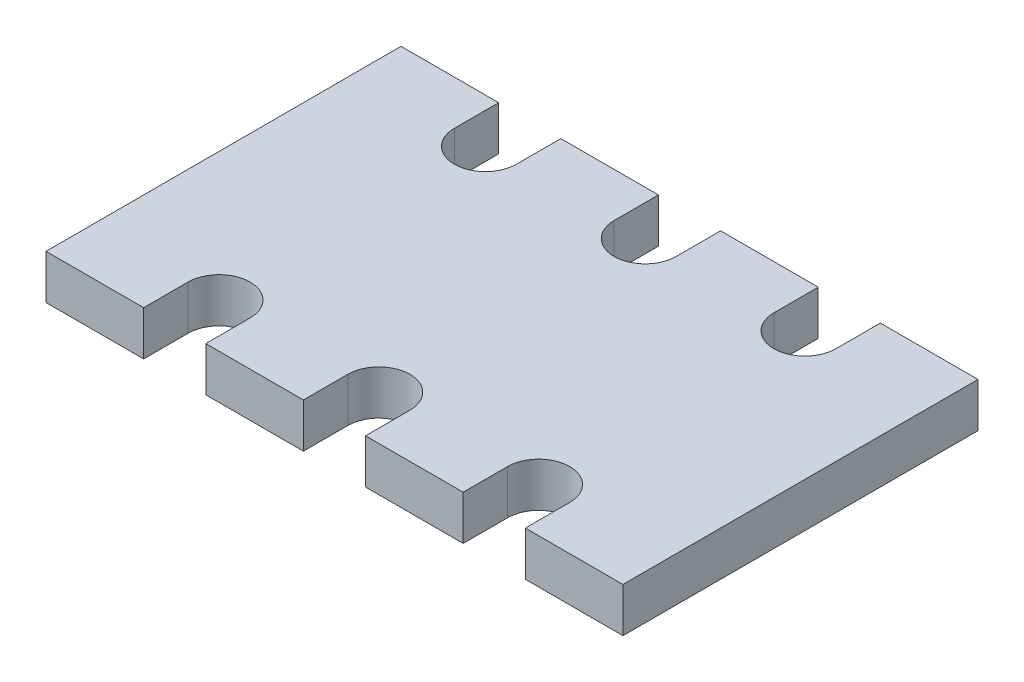
from build123d import *

# Parameters (mm, degrees)
BOSS_EXTRUDE1_DEPTH = 0.5


with BuildPart() as part:
    # Sketch1 → Boss-Extrude1 (new body)
    with BuildSketch(Plane(origin=(0, 0, 0), x_dir=(1, 0, 0), z_dir=(0, 1, 0))):
        with BuildLine():
            Line((-5.4, 0), (-5.4, -0.5))
            ThreePointArc((-5.4, -0.5), (-5.05, -0.85), (-4.7, -0.5))
            Line((-4.7, -0.5), (-4.7, 0))
            Line((-4.7, 0), (-3.6, 0))
            Line((-3.6, 0), (-3.6, -0.5))
            ThreePointArc((-3.6, -0.5), (-3.25, -0.85), (-2.9, -0.5))
            Line((-2.9, -0.5), (-2.9, 0))
            Line((-2.9, 0), (-1.8, 0))
            Line((-1.8, 0), (-1.8, -0.5))
            ThreePointArc((-1.8, -0.5), (-1.45, -0.85), (-1.1, -0.5))
            Line((-1.1, -0.5), (-1.1, 0))
            Line((-1.1, 0), (0, 0))
            Line((0, 0), (0, -4))
            Line((0, -4), (-1.1, -4))
            Line((-1.1, -4), (-1.1, -3.5))
            ThreePointArc((-1.1, -3.5), (-1.45, -3.15), (-1.8, -3.5))
            Line((-1.8, -3.5), (-1.8, -4))
            Line((-1.8, -4), (-2.9, -4))
            Line((-2.9, -4), (-2.9, -3.5))
            ThreePointArc((-2.9, -3.5), (-3.25, -3.15), (-3.6, -3.5))
            Line((-3.6, -3.5), (-3.6, -4))
            Line((-3.6, -4), (-4.7, -4))
            Line((-4.7, -4), (-4.7, -3.5))
            ThreePointArc((-4.7, -3.5), (-5.05, -3.15), (-5.4, -3.5))
            Line((-5.4, -3.5), (-5.4, -4))
            Line((-5.4, -4), (-6.5, -4))
            Line((-6.5, -4), (-6.5, 0))
            Line((-6.5, 0), (-5.4, 0))
        make_face()
    extrude(amount=BOSS_EXTRUDE1_DEPTH)


solid = part.part
